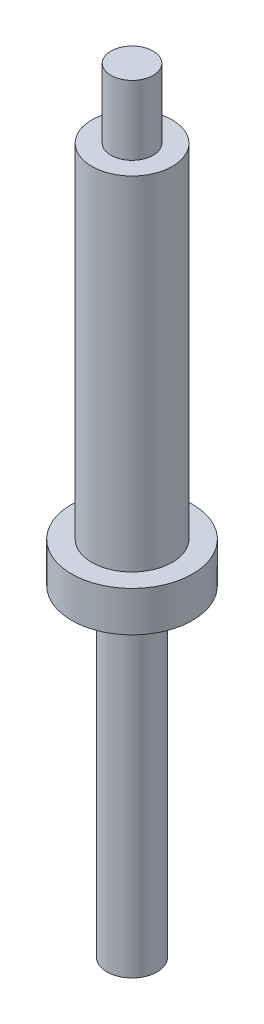
from build123d import *

# Parameters (mm, degrees)
SKETCH2_R           = 4.7625
BOSS_EXTRUDE1_DEPTH = 3.175


with BuildPart() as part:
    # Sketch1 → Revolve1 (revolve)
    with BuildSketch(Plane.XY, mode=Mode.PRIVATE) as revolve1_sk:
        Polygon((0, 0), (1.9812, 0), (1.9812, 25.4), (3.175, 25.4), (3.175, 55.626), (1.6637, 55.626), (1.6637, 61.087), (0, 61.087), align=None)
    revolve(revolve1_sk.sketch.rotate(Axis((0, 0, 0), (0, 1, 0)), 90), axis=Axis((0, 0, 0), (0, 1, 0)))  # turned: the seam where the file's is

    # Sketch2 → Boss-Extrude1 (add)
    with BuildSketch(Plane.XZ.offset(-25.4)):
        with Locations(Location((0, 0, 0), (0, 0, 270))):  # turned: the seam where the file's is
            Circle(SKETCH2_R)
    extrude(amount=-BOSS_EXTRUDE1_DEPTH)


solid = part.part
